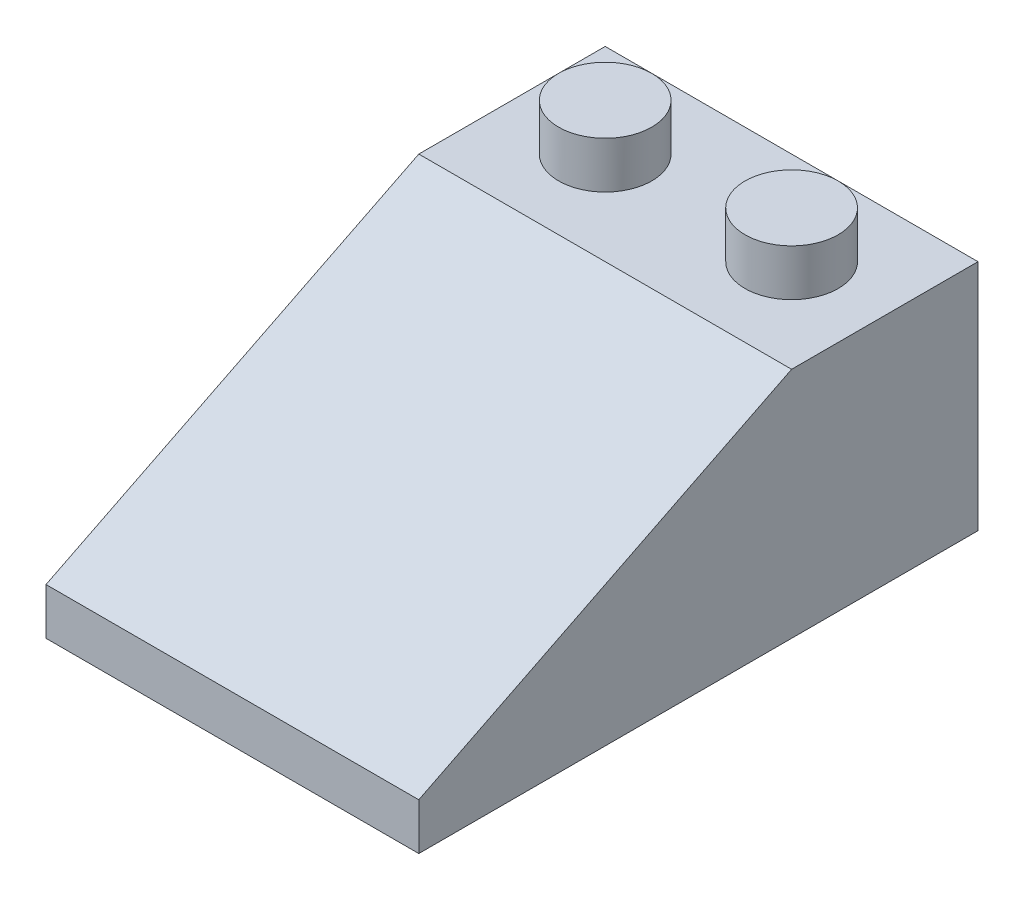
from build123d import *

# Parameters (mm, degrees)
BOSS_EXTRUDE1_DEPTH = 16
SKETCH2_R           = 2
BOSS_EXTRUDE2_DEPTH = 2
SHELL1_T            = -1
BOSS_EXTRUDE3_REACH = 14
SKETCH3_R           = 2.7
SKETCH3_R_2         = 1.7


with BuildPart() as part:
    # Sketch1 → Boss-Extrude1 (new body)
    with BuildSketch(Plane(origin=(0, 0, 0), x_dir=(0, 0, -1), z_dir=(1, 0, 0))):
        Polygon((0, 0), (0, 10), (-8, 10), (-24, 2), (-24, 0), align=None)
    extrude(amount=BOSS_EXTRUDE1_DEPTH)

    # Sketch2 → Boss-Extrude2 (add)
    with BuildSketch(Plane(origin=(0, 10, 0), x_dir=(1, 0, 0), z_dir=(0, 1, 0))):
        with Locations((4, -4)):
            Circle(SKETCH2_R)
        with Locations((12, -4)):
            Circle(SKETCH2_R)
    extrude(amount=BOSS_EXTRUDE2_DEPTH)

    # Shell1
    shell1_openings = [part.faces().sort_by_distance(p)[0] for p in [
        (8, 0, 12),
    ]]
    offset(amount=SHELL1_T, openings=shell1_openings, kind=Kind.INTERSECTION)

    # Sketch3 → Boss-Extrude3 (add, up to next)
    with BuildSketch(Plane.XZ, mode=Mode.PRIVATE) as boss_extrude3_sk1:
        with Locations((8, 8)):
            Circle(SKETCH3_R)
        with Locations((8, 8)):
            Circle(SKETCH3_R_2, mode=Mode.SUBTRACT)
    boss_extrude3_tool1 = extrude(boss_extrude3_sk1.sketch, amount=-BOSS_EXTRUDE3_REACH, mode=Mode.PRIVATE) - part.part
    add(boss_extrude3_tool1.solids().sort_by_distance((5.376368, 0, 8))[0])
    # Sketch3 → Boss-Extrude3 (add, up to next)
    with BuildSketch(Plane.XZ, mode=Mode.PRIVATE) as boss_extrude3_sk2:
        with Locations((8, 16)):
            Circle(SKETCH3_R)
        with Locations((8, 16)):
            Circle(SKETCH3_R_2, mode=Mode.SUBTRACT)
    boss_extrude3_tool2 = extrude(boss_extrude3_sk2.sketch, amount=-BOSS_EXTRUDE3_REACH, mode=Mode.PRIVATE) - part.part
    add(boss_extrude3_tool2.solids().sort_by_distance((5.376368, 0, 16))[0])


solid = part.part
